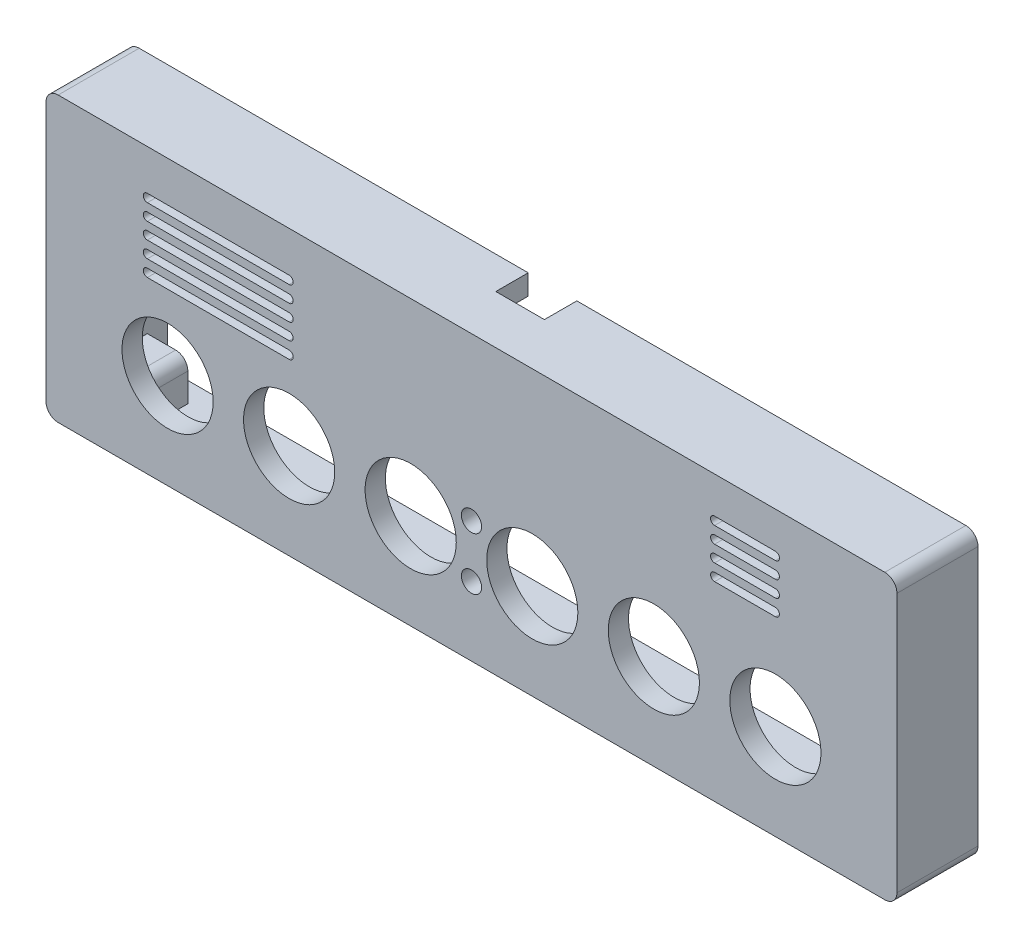
from build123d import *

# Parameters (mm, degrees)
SKETCH_1_W          = 210
SKETCH_1_H          = 70
EXTRUDE_1_DEPTH     = 20
FILLET_1_R          = 3
SKETCH_2_W          = 190
SKETCH_2_H          = 60
CUT_EXTRUDE_1_DEPTH = 15
SKETCH_3_R          = 1.5
CUT_EXTRUDE_2_DEPTH = 8
SKETCH_4_W          = 12
SKETCH_4_H          = 8
CUT_EXTRUDE_3_DEPTH = 5
SKETCH_5_R          = 11.25
SKETCH_5_R_2        = 2.5
CUT_EXTRUDE_4_DEPTH = 10
EXTRUDE_2_DEPTH     = 10
SKETCH_8_R          = 1.5
CUT_EXTRUDE_5_DEPTH = 8


with BuildPart() as part:
    # 草图1 → 凸台-拉伸1 (new body)
    with BuildSketch(Plane.XY):
        with Locations((75, 11.5)):
            Rectangle(SKETCH_1_W, SKETCH_1_H)
    extrude(amount=EXTRUDE_1_DEPTH)

    # 圆角1
    fillet_1_edges = [part.edges().sort_by_distance(p)[0] for p in [
        (-30, 46.5, 10),
        (180, 46.5, 10),
        (180, -23.5, 10),
        (-30, -23.5, 10),
    ]]
    fillet(fillet_1_edges, radius=FILLET_1_R)

    # 草图2 → 切除-拉伸1 (cut)
    with BuildSketch(Plane.XY):
        with Locations((75, 11.5)):
            Rectangle(SKETCH_2_W, SKETCH_2_H)
    extrude(amount=CUT_EXTRUDE_1_DEPTH, mode=Mode.SUBTRACT)

    # 草图3 → 切除-拉伸2 (cut)
    with BuildSketch(Plane.XY):
        with Locations((-25, 36.5)):
            Circle(SKETCH_3_R)
        with Locations((175, 36.5)):
            Circle(SKETCH_3_R)
        with Locations((-25, -13.5)):
            Circle(SKETCH_3_R)
        with Locations((175, -13.5)):
            Circle(SKETCH_3_R)
    extrude(amount=CUT_EXTRUDE_2_DEPTH, mode=Mode.SUBTRACT)

    # 草图4 → 切除-拉伸3 (cut)
    with BuildSketch(Plane(origin=(0, 46.5, 0), x_dir=(1, 0, 0), z_dir=(0, 1, 0))):
        with Locations((75, -4)):
            Rectangle(SKETCH_4_W, SKETCH_4_H)
    extrude(amount=-CUT_EXTRUDE_3_DEPTH, mode=Mode.SUBTRACT)

    # 草图5 → 切除-拉伸4 (cut)
    with BuildSketch(Plane.XY.offset(20)):
        Circle(SKETCH_5_R)
        with Locations((30, 0)):
            Circle(SKETCH_5_R)
        with Locations((60, 0)):
            Circle(SKETCH_5_R)
        with Locations((90, 0)):
            Circle(SKETCH_5_R)
        with Locations((120, 0)):
            Circle(SKETCH_5_R)
        with Locations((150, 0)):
            Circle(SKETCH_5_R)
        with Locations((75, -6.5)):
            Circle(SKETCH_5_R_2)
        with Locations((75, 6.5)):
            Circle(SKETCH_5_R_2)
        with BuildLine():
            Line((-5, 36.5), (30, 36.5))
            ThreePointArc((30, 36.5), (31, 35.5), (30, 34.5))
            Line((30, 34.5), (-5, 34.5))
            ThreePointArc((-5, 34.5), (-6, 35.5), (-5, 36.5))
        make_face()
        with BuildLine():
            Line((-5, 32.5), (30, 32.5))
            ThreePointArc((30, 32.5), (31, 31.5), (30, 30.5))
            Line((30, 30.5), (-5, 30.5))
            ThreePointArc((-5, 30.5), (-6, 31.5), (-5, 32.5))
        make_face()
        with BuildLine():
            Line((-5, 28.5), (30, 28.5))
            ThreePointArc((30, 28.5), (31, 27.5), (30, 26.5))
            Line((30, 26.5), (-5, 26.5))
            ThreePointArc((-5, 26.5), (-6, 27.5), (-5, 28.5))
        make_face()
        with BuildLine():
            Line((-5, 24.5), (30, 24.5))
            ThreePointArc((30, 24.5), (31, 23.5), (30, 22.5))
            Line((30, 22.5), (-5, 22.5))
            ThreePointArc((-5, 22.5), (-6, 23.5), (-5, 24.5))
        make_face()
        with BuildLine():
            Line((-5, 20.5), (30, 20.5))
            ThreePointArc((30, 20.5), (31, 19.5), (30, 18.5))
            Line((30, 18.5), (-5, 18.5))
            ThreePointArc((-5, 18.5), (-6, 19.5), (-5, 20.5))
        make_face()
        with BuildLine():
            Line((135, 37.5), (150, 37.5))
            ThreePointArc((150, 37.5), (151, 36.5), (150, 35.5))
            Line((150, 35.5), (135, 35.5))
            ThreePointArc((135, 35.5), (134, 36.5), (135, 37.5))
        make_face()
        with BuildLine():
            Line((135, 33.5), (150, 33.5))
            ThreePointArc((150, 33.5), (151, 32.5), (150, 31.5))
            Line((150, 31.5), (135, 31.5))
            ThreePointArc((135, 31.5), (134, 32.5), (135, 33.5))
        make_face()
        with BuildLine():
            Line((135, 29.5), (150, 29.5))
            ThreePointArc((150, 29.5), (151, 28.5), (150, 27.5))
            Line((150, 27.5), (135, 27.5))
            ThreePointArc((135, 27.5), (134, 28.5), (135, 29.5))
        make_face()
        with BuildLine():
            Line((135, 25.5), (150, 25.5))
            ThreePointArc((150, 25.5), (151, 24.5), (150, 23.5))
            Line((150, 23.5), (135, 23.5))
            ThreePointArc((135, 23.5), (134, 24.5), (135, 25.5))
        make_face()
    extrude(amount=-CUT_EXTRUDE_4_DEPTH, mode=Mode.SUBTRACT)

    # 草图6 → 凸台-拉伸2 (add)
    with BuildSketch(Plane.XY.offset(15)):
        with BuildLine():
            Line((-20, 31.5), (-13, 31.5))
            ThreePointArc((-13, 31.5), (-10.878679656, 32.378679656), (-10, 34.5))
            Line((-10, 34.5), (-10, 41.5))
            Line((-10, 41.5), (-20, 41.5))
            Line((-20, 41.5), (-20, 31.5))
        make_face()
        with BuildLine():
            Line((170, 41.5), (170, 31.5))
            Line((170, 31.5), (163, 31.5))
            ThreePointArc((163, 31.5), (160.878679656, 32.378679656), (160, 34.5))
            Line((160, 34.5), (160, 41.5))
            Line((160, 41.5), (170, 41.5))
        make_face()
        with BuildLine():
            Line((-20, -8.5), (-13, -8.5))
            ThreePointArc((-13, -8.5), (-10.878679656, -9.378679656), (-10, -11.5))
            Line((-10, -11.5), (-10, -18.5))
            Line((-10, -18.5), (-20, -18.5))
            Line((-20, -18.5), (-20, -8.5))
        make_face()
        with BuildLine():
            Line((170, -18.5), (160, -18.5))
            Line((160, -18.5), (160, -11.5))
            ThreePointArc((160, -11.5), (160.878679656, -9.378679656), (163, -8.5))
            Line((163, -8.5), (170, -8.5))
            Line((170, -8.5), (170, -18.5))
        make_face()
    extrude(amount=-EXTRUDE_2_DEPTH)

    # 草图8 → 切除-拉伸5 (cut)
    with BuildSketch(Plane(origin=(0, 0, 5), x_dir=(-1, 0, 0), z_dir=(0, 0, -1))):
        with Locations((-165, 36.5)):
            Circle(SKETCH_8_R)
        with Locations((15, 36.5)):
            Circle(SKETCH_8_R)
        with Locations((-165, -13.5)):
            Circle(SKETCH_8_R)
        with Locations((15, -13.5)):
            Circle(SKETCH_8_R)
    extrude(amount=-CUT_EXTRUDE_5_DEPTH, mode=Mode.SUBTRACT)


solid = part.part
